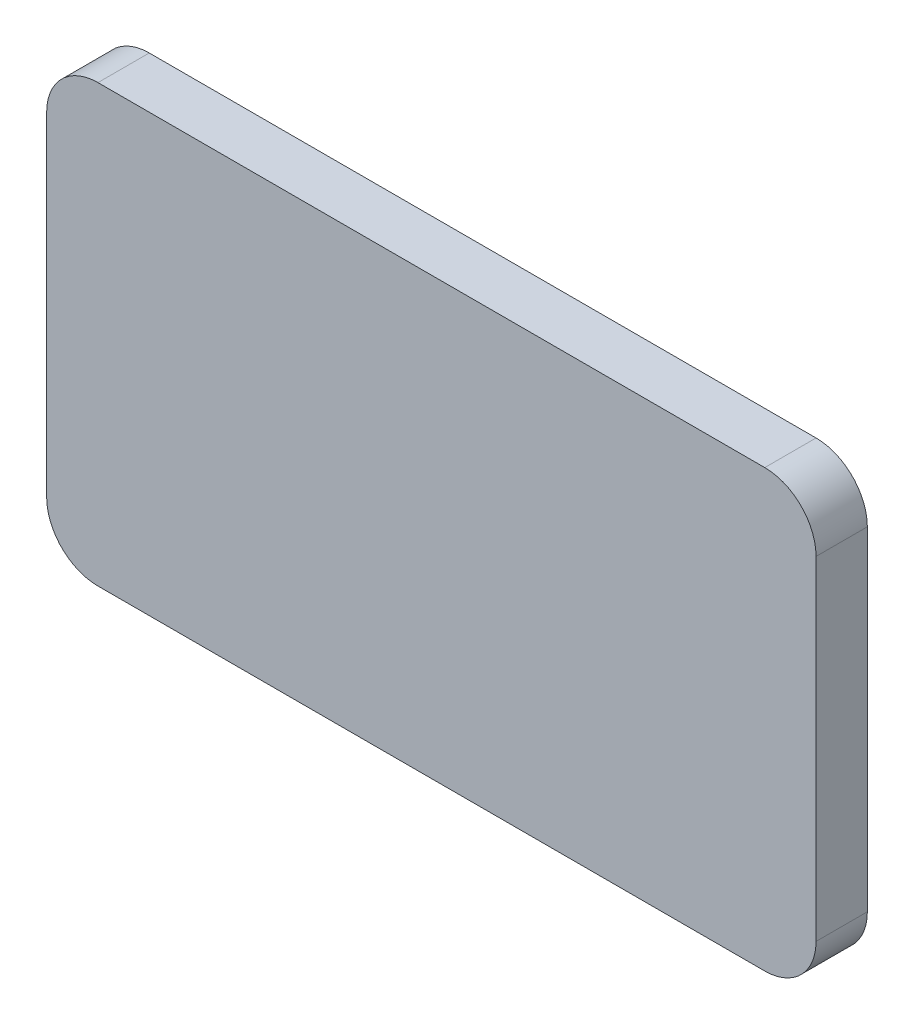
from build123d import *

# Parameters (mm, degrees)
SKETCH_1_W      = 30
SKETCH_1_H      = 17
EXTRUDE_1_DEPTH = 2
FILLET_1_R      = 2


with BuildPart() as part:
    # 스케치1 → 보스-돌출1 (new body)
    with BuildSketch(Plane.XY):
        with Locations((15, -8.5)):
            Rectangle(SKETCH_1_W, SKETCH_1_H)
    extrude(amount=EXTRUDE_1_DEPTH)

    # 필렛1
    fillet_1_edges = [part.edges().sort_by_distance(p)[0] for p in [
        (0, 0, 1),
        (30, 0, 1),
        (30, -17, 1),
        (0, -17, 1),
    ]]
    fillet(fillet_1_edges, radius=FILLET_1_R)


solid = part.part
